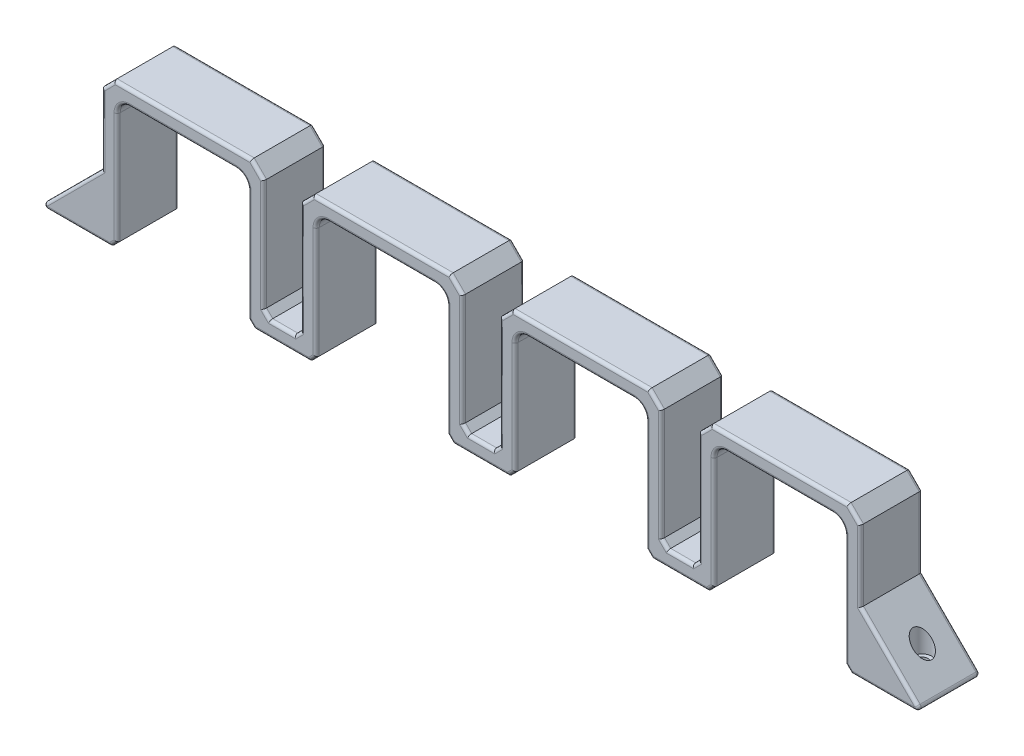
from build123d import *

# Parameters (mm, degrees)
BOSS_EXTRUDE2_DEPTH = 20
BOSS_EXTRUDE3_DEPTH = 20
SKETCH3_R           = 1.75
CUT_EXTRUDE1_DEPTH  = 48
SKETCH4_R           = 3
CUT_EXTRUDE2_DEPTH  = 42
FILLET1_R           = 4
CHAMFER1_SIZE       = 4
SKETCH5_R           = 1.75
CUT_EXTRUDE3_DEPTH  = 6
FILLET2_R           = 1
CHAMFER2_SIZE       = 2
FILLET3_R           = 1


with BuildPart() as part:
    # Sketch1 → Boss-Extrude2 (new body)
    with BuildSketch(Plane.XY):
        Polygon((-26.15, 26), (26.15, 26), (26.15, -16), (38.15, -16), (38.15, 26), (90.45, 26), (90.45, -16), (102.45, -16), (102.45, 26), (154.75, 26), (154.75, -16), (166.75, -16), (166.75, 26), (219.05, 26), (219.05, -21), (214.05, -21), (214.05, 21), (171.75, 21), (171.75, -21), (149.75, -21), (149.75, 21), (107.45, 21), (107.45, -21), (85.45, -21), (85.45, 21), (43.15, 21), (43.15, -21), (21.15, -21), (21.15, 21), (-21.15, 21), (-21.15, -21), (-26.15, -21), align=None)
    extrude(amount=BOSS_EXTRUDE2_DEPTH)

    # Sketch2 → Boss-Extrude3 (add)
    with BuildSketch(Plane.XY.offset(20)):
        Polygon((-26.15, -1), (-46.15, -21), (-26.15, -21), align=None)
        Polygon((219.05, -21), (239.05, -21), (219.05, -1), align=None)
    extrude(amount=-BOSS_EXTRUDE3_DEPTH)

    # Sketch3 → Cut-Extrude1 (cut, through all)
    with BuildSketch(Plane(origin=(0, 26, 0), x_dir=(1, 0, 0), z_dir=(0, 1, 0))):
        with Locations((-36.15, -10)):
            Circle(SKETCH3_R)
        with Locations((229.05, -10)):
            Circle(SKETCH3_R)
    extrude(amount=-CUT_EXTRUDE1_DEPTH, mode=Mode.SUBTRACT)

    # Sketch4 → Cut-Extrude2 (cut)
    with BuildSketch(Plane(origin=(0, 26, 0), x_dir=(1, 0, 0), z_dir=(0, 1, 0))):
        with Locations((-36.15, -10)):
            Circle(SKETCH4_R)
        with Locations((229.05, -10)):
            Circle(SKETCH4_R)
    extrude(amount=-CUT_EXTRUDE2_DEPTH, mode=Mode.SUBTRACT)

    # Fillet1
    fillet1_edges = [part.edges().sort_by_distance(p)[0] for p in [
        (214.05, 21, 10),
        (171.75, 21, 10),
        (149.75, 21, 10),
        (107.45, 21, 10),
        (85.45, 21, 10),
        (43.15, 21, 10),
        (21.15, 21, 10),
        (-21.15, 21, 10),
    ]]
    fillet(fillet1_edges, radius=FILLET1_R)

    # Chamfer1
    chamfer1_edges = [part.edges().sort_by_distance(p)[0] for p in [
        (-26.15, 26, 10),
        (26.15, 26, 10),
        (38.15, 26, 10),
        (90.45, 26, 10),
        (102.45, 26, 10),
        (154.75, 26, 10),
        (166.75, 26, 10),
        (219.05, 26, 10),
    ]]
    chamfer(chamfer1_edges, length=CHAMFER1_SIZE)

    # Sketch5 → Cut-Extrude3 (cut, through all)
    with BuildSketch(Plane(origin=(0, -16, 0), x_dir=(1, 0, 0), z_dir=(0, 1, 0))):
        with Locations((32.15, -10)):
            Circle(SKETCH5_R)
        with Locations((96.45, -10)):
            Circle(SKETCH5_R)
        with Locations((160.75, -10)):
            Circle(SKETCH5_R)
    extrude(amount=-CUT_EXTRUDE3_DEPTH, mode=Mode.SUBTRACT)

    # Fillet2
    fillet2_edges = [part.edges().sort_by_distance(p)[0] for p in [
        (239.05, -21, 10),
        (-46.15, -21, 10),
    ]]
    fillet(fillet2_edges, radius=FILLET2_R)

    # Chamfer2
    chamfer2_edges = [part.edges().sort_by_distance(p)[0] for p in [
        (-21.15, -21, 10),
        (26.15, -16, 10),
        (38.15, -16, 10),
        (90.45, -16, 10),
        (102.45, -16, 10),
        (154.75, -16, 10),
        (166.75, -16, 10),
        (214.05, -21, 10),
        (171.75, -21, 10),
        (149.75, -21, 10),
        (107.45, -21, 10),
        (85.45, -21, 10),
        (43.15, -21, 10),
        (21.15, -21, 10),
    ]]
    chamfer(chamfer2_edges, length=CHAMFER2_SIZE)

    # Fillet3
    fillet3_edges = [part.edges().sort_by_distance(p)[0] for p in [
        (214.05, -1, 0),
        (214.05, -1, 20),
        (192.9, 21, 0),
        (192.9, 21, 20),
        (149.75, -1, 0),
        (149.75, -1, 20),
        (128.6, 21, 0),
        (128.6, 21, 20),
        (85.45, -1, 0),
        (85.45, -1, 20),
        (64.3, 21, 0),
        (64.3, 21, 20),
        (21.15, -1, 0),
        (21.15, -1, 20),
        (0, 21, 0),
        (0, 21, 20),
        (212.878427125, 19.828427125, 0),
        (212.878427125, 19.828427125, 20),
        (172.921572875, 19.828427125, 0),
        (172.921572875, 19.828427125, 20),
        (148.578427125, 19.828427125, 0),
        (148.578427125, 19.828427125, 20),
        (108.621572875, 19.828427125, 0),
        (108.621572875, 19.828427125, 20),
        (84.278427125, 19.828427125, 0),
        (84.278427125, 19.828427125, 20),
        (44.321572875, 19.828427125, 0),
        (44.321572875, 19.828427125, 20),
        (19.978427125, 19.828427125, 0),
        (19.978427125, 19.828427125, 20),
        (-19.978427125, 19.828427125, 0),
        (-19.978427125, 19.828427125, 20),
        (192.9, 26, 0),
        (192.9, 26, 20),
        (-26.15, 10.5, 0),
        (0, 26, 0),
        (38.15, 4, 0),
        (64.3, 26, 0),
        (102.45, 4, 0),
        (128.6, 26, 0),
        (166.75, 4, 0),
        (-24.15, 24, 0),
        (24.15, 24, 0),
        (40.15, 24, 0),
        (88.45, 24, 0),
        (104.45, 24, 0),
        (168.75, 24, 0),
        (152.75, 24, 0),
        (217.05, 24, 0),
        (166.75, 4, 20),
        (128.6, 26, 20),
        (102.45, 4, 20),
        (64.3, 26, 20),
        (38.15, 4, 20),
        (0, 26, 20),
        (-26.15, 10.5, 20),
        (-24.15, 24, 20),
        (24.15, 24, 20),
        (40.15, 24, 20),
        (88.45, 24, 20),
        (104.45, 24, 20),
        (168.75, 24, 20),
        (152.75, 24, 20),
        (217.05, 24, 20),
        (-33.442893219, -21, 20),
        (228.196446609, -10.146446609, 20),
        (-44.65966597, -20.382683432, 20),
        (237.55966597, -20.382683432, 20),
        (228.196446609, -10.146446609, 0),
        (-33.442893219, -21, 0),
        (-44.65966597, -20.382683432, 0),
        (237.55966597, -20.382683432, 0),
        (226.342893219, -21, 0),
        (226.342893219, -21, 20),
        (171.75, -1, 0),
        (160.75, -21, 0),
        (107.45, -1, 0),
        (96.45, -21, 0),
        (43.15, -1, 0),
        (32.15, -21, 0),
        (-21.15, -1, 0),
        (26.15, 4, 0),
        (32.15, -16, 0),
        (90.45, 4, 0),
        (96.45, -16, 0),
        (154.75, 4, 0),
        (160.75, -16, 0),
        (22.15, -20, 0),
        (42.15, -20, 0),
        (86.45, -20, 0),
        (106.45, -20, 0),
        (150.75, -20, 0),
        (170.75, -20, 0),
        (-22.15, -20, 0),
        (215.05, -20, 0),
        (160.75, -16, 20),
        (154.75, 4, 20),
        (96.45, -16, 20),
        (90.45, 4, 20),
        (32.15, -16, 20),
        (26.15, 4, 20),
        (-21.15, -1, 20),
        (32.15, -21, 20),
        (43.15, -1, 20),
        (96.45, -21, 20),
        (107.45, -1, 20),
        (160.75, -21, 20),
        (171.75, -1, 20),
        (22.15, -20, 20),
        (42.15, -20, 20),
        (86.45, -20, 20),
        (106.45, -20, 20),
        (150.75, -20, 20),
        (170.75, -20, 20),
        (-22.15, -20, 20),
        (215.05, -20, 20),
        (165.75, -15, 0),
        (165.75, -15, 20),
        (155.75, -15, 0),
        (155.75, -15, 20),
        (91.45, -15, 0),
        (91.45, -15, 20),
        (101.45, -15, 0),
        (101.45, -15, 20),
        (37.15, -15, 0),
        (37.15, -15, 20),
        (27.15, -15, 0),
        (27.15, -15, 20),
        (-35.296446609, -10.146446609, 0),
        (-35.296446609, -10.146446609, 20),
        (219.05, 10.5, 0),
        (219.05, 10.5, 20),
    ]]
    fillet(fillet3_edges, radius=FILLET3_R)


solid = part.part
